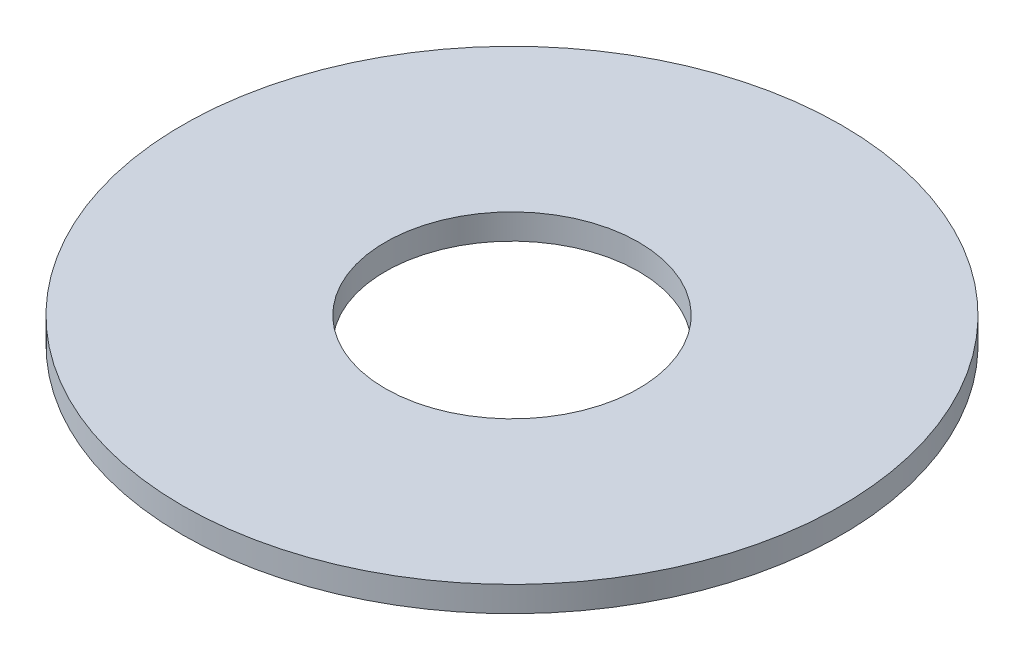
from build123d import *

# Parameters (mm, degrees)
SKETCH1_R           = 41.275
SKETCH1_R_2         = 15.875
BOSS_EXTRUDE1_DEPTH = 3.175


with BuildPart() as part:
    # Sketch1 → Boss-Extrude1 (new body)
    with BuildSketch(Plane(origin=(0, 0, 0), x_dir=(1, 0, 0), z_dir=(0, 1, 0))):
        Circle(SKETCH1_R)
        Circle(SKETCH1_R_2, mode=Mode.SUBTRACT)
    extrude(amount=BOSS_EXTRUDE1_DEPTH)


solid = part.part
